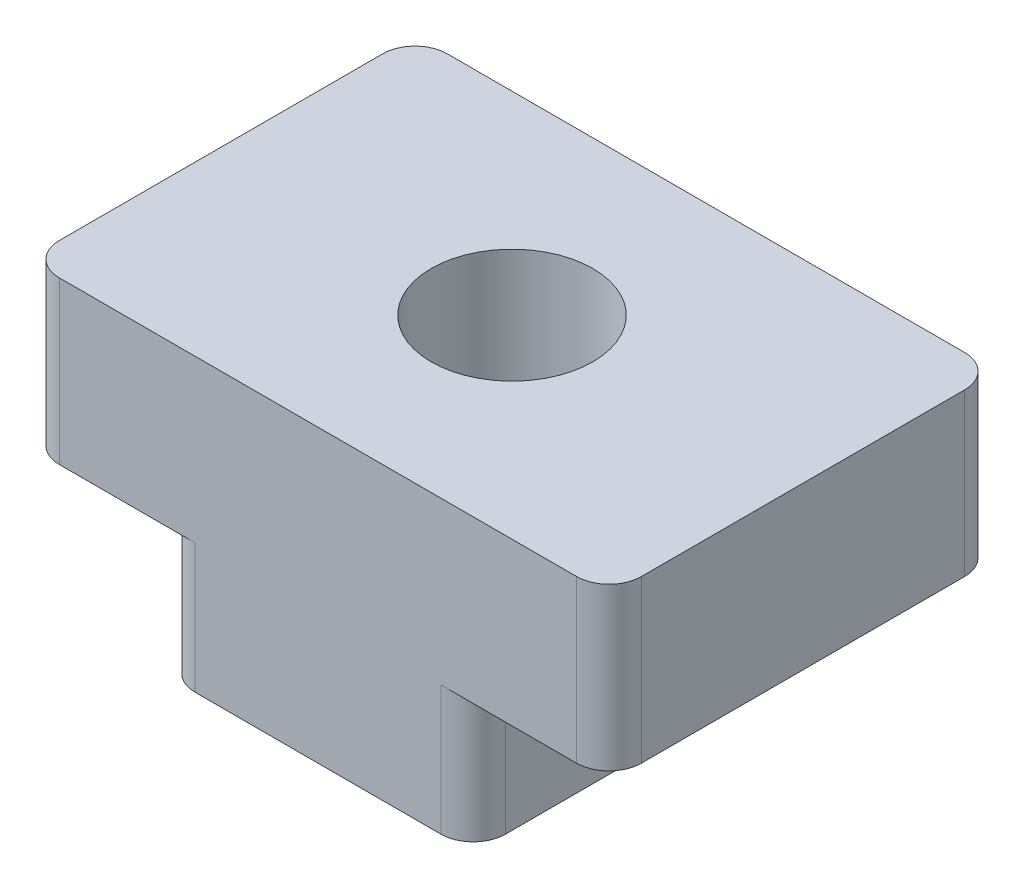
from build123d import *

# Parameters (mm, degrees)
BOSS_EXTRU_1_DEPTH      = 3
ESQUISSE2_R             = 1.25
ENL_V_MAT_EXTRU_1_DEPTH = 5.5
CONG_1_R                = 0.5


with BuildPart() as part:
    # Esquisse1 → Boss.-Extru.1 (new body, symmetric)
    with BuildSketch(Plane.XY):
        Polygon((-4.5, 0), (-2.4, 0), (-2.4, -2), (2.4, -2), (2.4, 0), (4.5, 0), (4.5, 2.5), (-4.5, 2.5), align=None)
    extrude(amount=BOSS_EXTRU_1_DEPTH, both=True)

    # Esquisse2 → Enlèv. mat.-Extru.1 (cut, through all)
    with BuildSketch(Plane(origin=(0, 2.5, 0), x_dir=(1, 0, 0), z_dir=(0, 1, 0))):
        Circle(ESQUISSE2_R)
    extrude(amount=-ENL_V_MAT_EXTRU_1_DEPTH, mode=Mode.SUBTRACT)

    # Congé1
    cong_1_edges = [part.edges().sort_by_distance(p)[0] for p in [
        (-4.5, 1.25, -3),
        (4.5, 1.25, -3),
        (-4.5, 1.25, 3),
        (-2.4, -1, 3),
        (2.4, -1, 3),
        (4.5, 1.25, 3),
        (2.4, -1, -3),
        (-2.4, -1, -3),
    ]]
    fillet(cong_1_edges, radius=CONG_1_R)


solid = part.part
